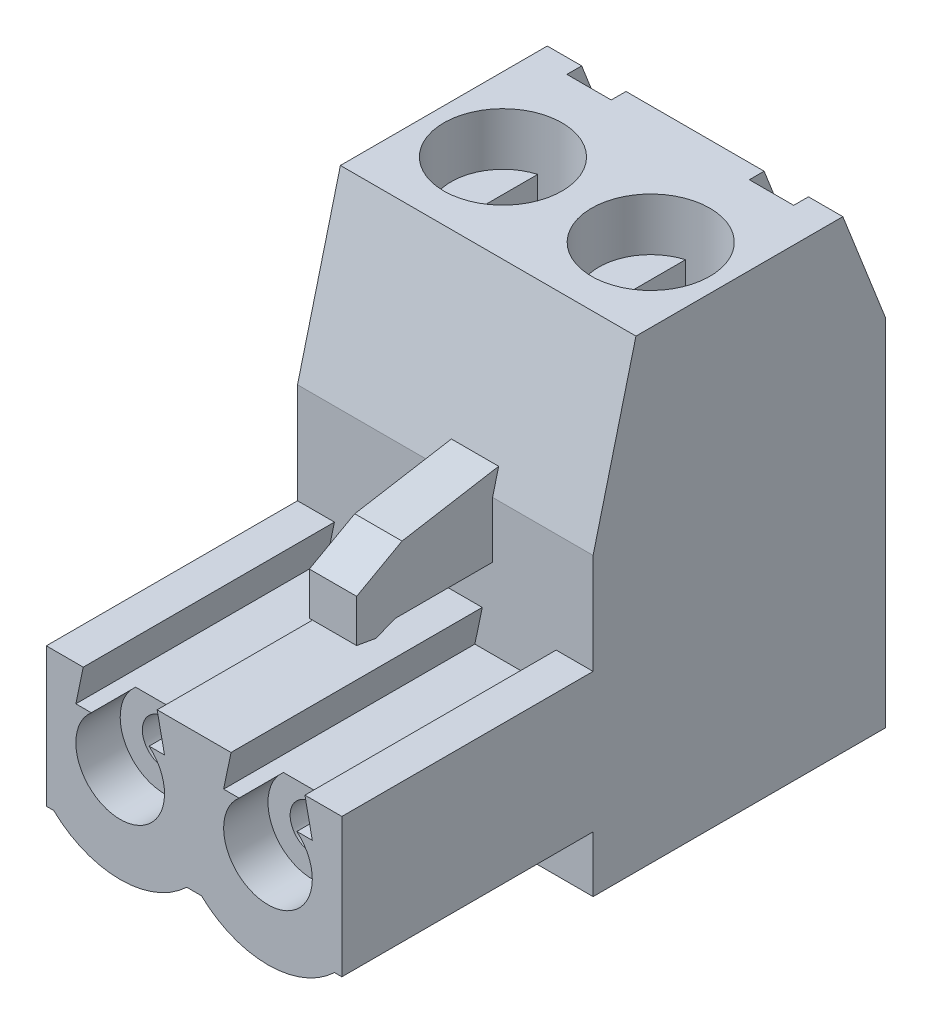
from build123d import *

# Parameters (mm, degrees)
AUFSATZ_LINEAR_AUSTRAGEN1_DEPTH             = 10
AUFSATZ_LINEAR_START                        = -9.9
AUFSATZ_LINEAR_AUSTRAGEN2_DEPTH             = 18.4
SCHNITT_LINEAR_AUSTRAGEN1_DEPTH             = 8.5
SKIZZE4_R                                   = 1.5
SCHNITT_LINEAR_AUSTRAGEN2_DEPTH             = 1.5
AUFSATZ_LINEAR_AUSTRAGEN4_DEPTH             = 10
SCHNITT_LINEAR_AUSTRAGEN3_REACH             = 11.9
SKIZZE6_W                                   = 5
SKIZZE6_H                                   = 8.452104708
SKIZZE6_W_2                                 = 3.4
SCHNITT_LINEAR_AUSTRAGEN3_DIRECTION_2_DEPTH = 9.5
SKIZZE7_W                                   = 1.5
SKIZZE7_H                                   = 1
SCHNITT_LINEAR_AUSTRAGEN4_DEPTH             = 1.5
SKIZZE8_R                                   = 2
SCHNITT_LINEAR_AUSTRAGEN5_DEPTH             = 4
SKIZZE9_W                                   = 3
SKIZZE9_H                                   = 4
SCHNITT_LINEAR_AUSTRAGEN6_DEPTH             = 5
SKIZZE10_R                                  = 0.75
SCHNITT_LINEAR_AUSTRAGEN7_DEPTH             = 7
FASE1_SIZE                                  = 2
SKIZZE11_W                                  = 3
SKIZZE11_H                                  = 2.45
SKIZZE11_H_2                                = 2.5
AUFSATZ_LINEAR_AUSTRAGEN5_DEPTH             = 3
SKIZZE12_R                                  = 1.75
AUFSATZ_LINEAR_AUSTRAGEN6_DEPTH             = 1.4
AUFSATZ_LINEAR_AUSTRAGEN7_DEPTH             = 1
AUFSATZ_LINEAR_AUSTRAGEN7_2_DEPTH           = 1
AUFSATZ_LINEAR_AUSTRAGEN7_3_DEPTH           = 1
AUFSATZ_LINEAR_AUSTRAGEN7_4_DEPTH           = 1


with BuildPart() as part:
    # Skizze1 → Aufsatz-Linear austragen1 (new body)
    with BuildSketch(Plane(origin=(0, 0, 0), x_dir=(0, 0, -1), z_dir=(1, 0, 0))):
        Polygon((3.5, 15.7), (-3.5, 15.7), (-4.95, 10), (-4.95, 0), (4.95, 0), (4.95, 12), align=None)
    extrude(amount=AUFSATZ_LINEAR_AUSTRAGEN1_DEPTH)

    # Skizze2 → Aufsatz-Linear austragen2 (add)
    with BuildSketch(Plane.XY.offset(4.95).offset(AUFSATZ_LINEAR_START)):
        with BuildLine():
            Line((4.75, 1.9), (5.25, 1.9))
            ThreePointArc((5.25, 1.9), (7.5, 1), (9.75, 1.9))
            Line((9.75, 1.9), (10, 1.9))
            Line((10, 1.9), (10, 6.6))
            Line((10, 6.6), (0, 6.6))
            Line((0, 6.6), (0, 1.9))
            Line((0, 1.9), (0.25, 1.9))
            ThreePointArc((0.25, 1.9), (2.5, 1), (4.75, 1.9))
        make_face()
    extrude(amount=AUFSATZ_LINEAR_AUSTRAGEN2_DEPTH)

    # Skizze3 → Schnitt-Linear austragen1 (cut)
    with BuildSketch(Plane.XY.offset(13.45)):
        Polygon((1.25, 6.6), (1, 5.4), (4, 5.4), (3.75, 6.6), align=None)
        Polygon((6.25, 6.6), (6, 5.4), (9, 5.4), (8.75, 6.6), align=None)
    extrude(amount=-SCHNITT_LINEAR_AUSTRAGEN1_DEPTH, mode=Mode.SUBTRACT)

    # Skizze4 → Schnitt-Linear austragen2 (cut)
    with BuildSketch(Plane.XY.offset(13.45)):
        with Locations((2.5, 4.2625)):
            Circle(SKIZZE4_R)
        with Locations((7.5, 4.2625)):
            Circle(SKIZZE4_R)
    extrude(amount=-SCHNITT_LINEAR_AUSTRAGEN2_DEPTH, mode=Mode.SUBTRACT)

    # Skizze5 → Aufsatz-Linear austragen4 (add, through all)
    with BuildSketch(Plane(origin=(10, 0, 0), x_dir=(0, 0, -1), z_dir=(1, 0, 0))):
        Polygon((-4.744529464, 10.807711762), (-8.014071378, 10.251051744), (-9.55, 9.4), (-9.55, 7.956699146), (-8.898693464, 7.842399632), (-8.247386929, 8.1), (-4.95, 8.1), (-4.95, 10), align=None)
    extrude(amount=-AUFSATZ_LINEAR_AUSTRAGEN4_DEPTH)

    # Schnitt-Linear austragen3: up to this face of the body (flat: up to its plane)
    schnitt_linear_austragen3_end = Plane(part.part.faces().sort_by_distance((5, 13.253855881, 4.122264732))[0])
    # Skizze6 → Schnitt-Linear austragen3 (cut, up to the picked face)
    with BuildSketch(Plane.XY.offset(4.95), mode=Mode.PRIVATE) as schnitt_linear_austragen3_sk1:
        with Locations((2.5, 11.473947646)):
            Rectangle(SKIZZE6_W, SKIZZE6_H)
    schnitt_linear_austragen3_tool1 = split(extrude(schnitt_linear_austragen3_sk1.sketch, amount=-SCHNITT_LINEAR_AUSTRAGEN3_REACH, mode=Mode.PRIVATE), bisect_by=schnitt_linear_austragen3_end, keep=Keep.BOTH, mode=Mode.PRIVATE)
    add(schnitt_linear_austragen3_tool1.solids().sort_by_distance((2.5, 11.473948, 4.95))[0], mode=Mode.SUBTRACT)
    # Skizze6 → Schnitt-Linear austragen3 (cut, up to the picked face)
    with BuildSketch(Plane.XY.offset(4.95), mode=Mode.PRIVATE) as schnitt_linear_austragen3_sk2:
        with Locations((8.3, 11.473947646)):
            Rectangle(SKIZZE6_W_2, SKIZZE6_H)
    schnitt_linear_austragen3_tool2 = split(extrude(schnitt_linear_austragen3_sk2.sketch, amount=-SCHNITT_LINEAR_AUSTRAGEN3_REACH, mode=Mode.PRIVATE), bisect_by=schnitt_linear_austragen3_end, keep=Keep.BOTH, mode=Mode.PRIVATE)
    add(schnitt_linear_austragen3_tool2.solids().sort_by_distance((8.3, 11.473948, 4.95))[0], mode=Mode.SUBTRACT)

    # Skizze6 → Schnitt-Linear austragen3 direction 2 (cut)
    with BuildSketch(Plane.XY.offset(4.95)):
        with Locations((2.5, 11.473947646)):
            Rectangle(SKIZZE6_W, SKIZZE6_H)
        with Locations((8.3, 11.473947646)):
            Rectangle(SKIZZE6_W_2, SKIZZE6_H)
    extrude(amount=SCHNITT_LINEAR_AUSTRAGEN3_DIRECTION_2_DEPTH, mode=Mode.SUBTRACT)

    # Skizze7 → Schnitt-Linear austragen4 (cut)
    with BuildSketch(Plane(origin=(0, 15.7, 0), x_dir=(1, 0, 0), z_dir=(0, 1, 0))):
        with Locations((1.913600435, 3.5)):
            Rectangle(SKIZZE7_W, SKIZZE7_H)
        with Locations((8.086399565, 3.5)):
            Rectangle(SKIZZE7_W, SKIZZE7_H)
    extrude(amount=-SCHNITT_LINEAR_AUSTRAGEN4_DEPTH, mode=Mode.SUBTRACT)

    # Skizze8 → Schnitt-Linear austragen5 (cut)
    with BuildSketch(Plane(origin=(0, 15.7, 0), x_dir=(1, 0, 0), z_dir=(0, 1, 0))):
        with Locations((2.5, -0.5)):
            Circle(SKIZZE8_R)
        with Locations((7.5, -0.5)):
            Circle(SKIZZE8_R)
    extrude(amount=-SCHNITT_LINEAR_AUSTRAGEN5_DEPTH, mode=Mode.SUBTRACT)

    # Skizze9 → Schnitt-Linear austragen6 (cut)
    with BuildSketch(Plane(origin=(0, 0, -4.95), x_dir=(-1, 0, 0), z_dir=(0, 0, -1))):
        with Locations((-7.5, 3.821692415)):
            Rectangle(SKIZZE9_W, SKIZZE9_H)
        with Locations((-2.5, 3.821692415)):
            Rectangle(SKIZZE9_W, SKIZZE9_H)
    extrude(amount=-SCHNITT_LINEAR_AUSTRAGEN6_DEPTH, mode=Mode.SUBTRACT)

    # Skizze10 → Schnitt-Linear austragen7 (cut)
    with BuildSketch(Plane.XY.offset(11.95)):
        with Locations((2.5, 4.2625)):
            Circle(SKIZZE10_R)
        with Locations((7.5, 4.2625)):
            Circle(SKIZZE10_R)
    extrude(amount=-SCHNITT_LINEAR_AUSTRAGEN7_DEPTH, mode=Mode.SUBTRACT)

    # Fase1
    fase1_edges = [part.edges().sort_by_distance(p)[0] for p in [
        (7.5, 5.821692415, -4.95),
        (2.5, 5.821692415, -4.95),
    ]]
    chamfer(fase1_edges, length=FASE1_SIZE)

    # Skizze11 → Aufsatz-Linear austragen5 (add)
    with BuildSketch(Plane(origin=(0, 1.821692415, 0), x_dir=(1, 0, 0), z_dir=(0, 1, 0))):
        with Locations((7.5, 1.225)):
            Rectangle(SKIZZE11_W, SKIZZE11_H)
        with Locations((2.5, 1.2)):
            Rectangle(SKIZZE11_W, SKIZZE11_H_2)
    extrude(amount=AUFSATZ_LINEAR_AUSTRAGEN5_DEPTH)

    # Skizze12 → Aufsatz-Linear austragen6 (add)
    with BuildSketch(Plane(origin=(0, 11.7, 0), x_dir=(1, 0, 0), z_dir=(0, 1, 0))):
        with Locations((7.5, -0.5)):
            Circle(SKIZZE12_R)
        with Locations((2.5, -0.5)):
            Circle(SKIZZE12_R)
    extrude(amount=AUFSATZ_LINEAR_AUSTRAGEN6_DEPTH)


with BuildPart() as body_2:
    # Skizze13 → Aufsatz-Linear austragen7 (new body)
    with BuildSketch(Plane(origin=(0, 13.1, 0), x_dir=(1, 0, 0), z_dir=(0, 1, 0))):
        with BuildLine():
            Line((2, 1.177050983), (2, -2.177050983))
            ThreePointArc((2, -2.177050983), (0.75, -0.5), (2, 1.177050983))
        make_face()
    extrude(amount=AUFSATZ_LINEAR_AUSTRAGEN7_DEPTH)


with BuildPart() as body_3:
    # Skizze13 → Aufsatz-Linear austragen7 2 (new body)
    with BuildSketch(Plane(origin=(0, 13.1, 0), x_dir=(1, 0, 0), z_dir=(0, 1, 0))):
        with BuildLine():
            Line((3, 1.177050983), (3, -2.177050983))
            ThreePointArc((3, -2.177050983), (4.25, -0.5), (3, 1.177050983))
        make_face()
    extrude(amount=AUFSATZ_LINEAR_AUSTRAGEN7_2_DEPTH)


with BuildPart() as body_4:
    # Skizze13 → Aufsatz-Linear austragen7 3 (new body)
    with BuildSketch(Plane(origin=(0, 13.1, 0), x_dir=(1, 0, 0), z_dir=(0, 1, 0))):
        with BuildLine():
            Line((7, 1.177050983), (7, -2.177050983))
            ThreePointArc((7, -2.177050983), (5.75, -0.5), (7, 1.177050983))
        make_face()
    extrude(amount=AUFSATZ_LINEAR_AUSTRAGEN7_3_DEPTH)


with BuildPart() as body_5:
    # Skizze13 → Aufsatz-Linear austragen7 4 (new body)
    with BuildSketch(Plane(origin=(0, 13.1, 0), x_dir=(1, 0, 0), z_dir=(0, 1, 0))):
        with BuildLine():
            Line((8, 1.177050983), (8, -2.177050983))
            ThreePointArc((8, -2.177050983), (9.25, -0.5), (8, 1.177050983))
        make_face()
    extrude(amount=AUFSATZ_LINEAR_AUSTRAGEN7_4_DEPTH)


solid = Compound([part.part, body_2.part, body_3.part, body_4.part, body_5.part])
